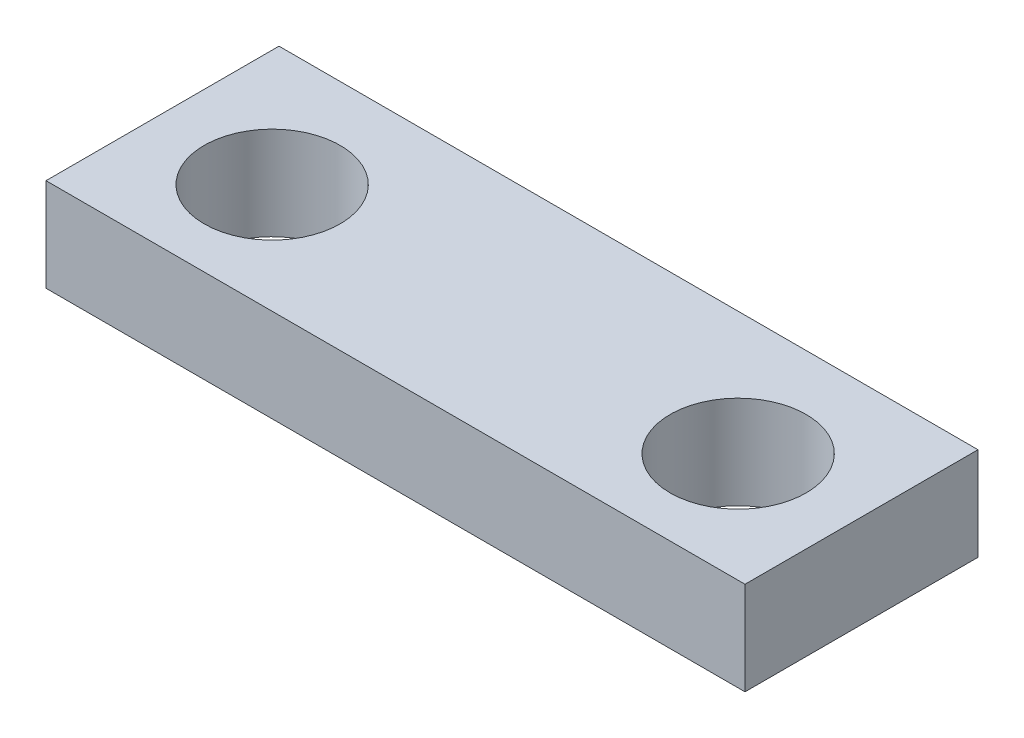
from build123d import *

# Parameters (mm, degrees)
SKETCH3_W           = 15
SKETCH3_H           = 5
SKETCH3_R           = 1.45951715
BOSS_EXTRUDE1_DEPTH = 2


with BuildPart() as part:
    # Sketch3 → Boss-Extrude1 (new body)
    with BuildSketch(Plane(origin=(0, 0, 0), x_dir=(1, 0, 0), z_dir=(0, 1, 0))):
        with Locations((0.441176471, -0.735294118)):
            Rectangle(SKETCH3_W, SKETCH3_H)
        with Locations((5.441176471, -0.882352941)):
            Circle(SKETCH3_R, mode=Mode.SUBTRACT)
        with Locations((-4.558823529, -0.882352941)):
            Circle(SKETCH3_R, mode=Mode.SUBTRACT)
    extrude(amount=-BOSS_EXTRUDE1_DEPTH)


solid = part.part
